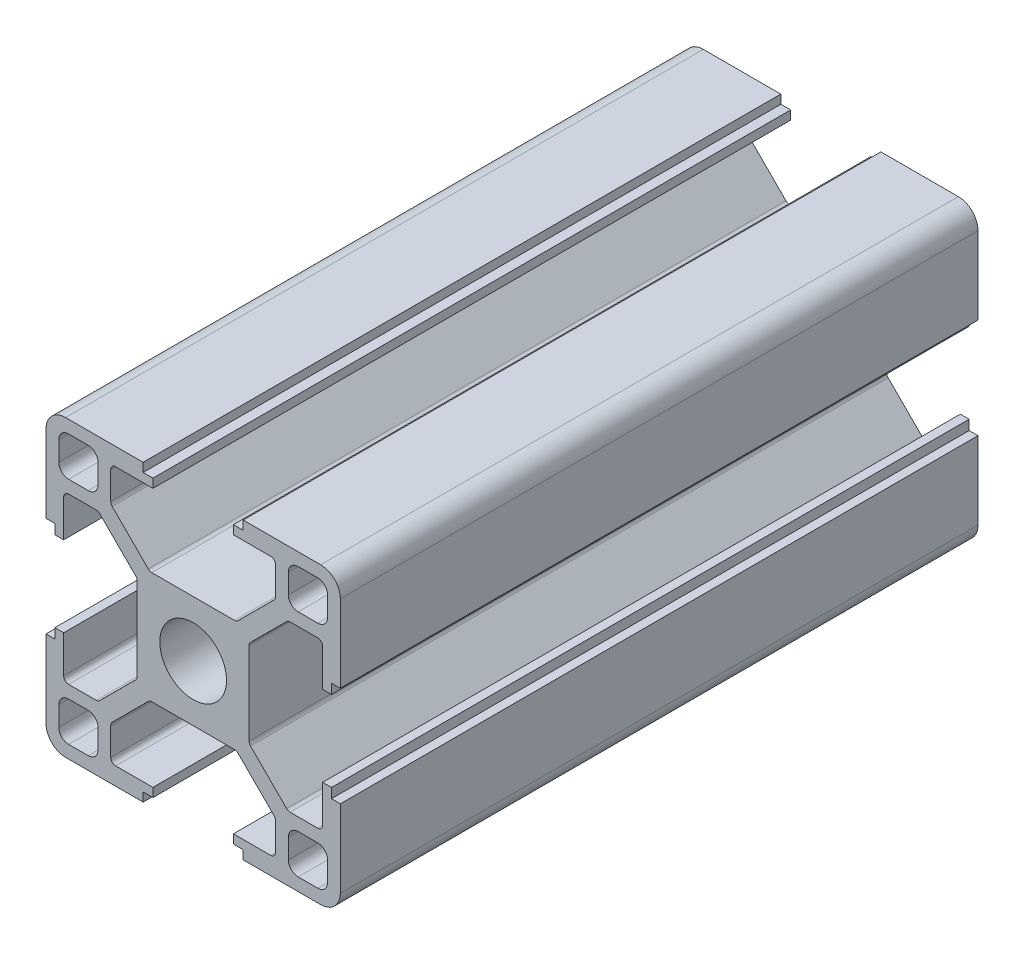
from build123d import *

# Parameters (mm, degrees)
SKETCH_1_W                       = 4
SKETCH_1_H                       = 4
EXTRUDE_1_DEPTH                  = 65
FILLET_1_R                       = 1
FILLET_2_R                       = 2
FILLET_3_R                       = 0.5
PATTERN_CIRCULAR_1_COUNT         = 4
FILLET_1_OF_PATTERN_CIRCULAR_1_R = 1
FILLET_2_OF_PATTERN_CIRCULAR_1_R = 2
FILLET_3_OF_PATTERN_CIRCULAR_1_R = 0.5
SKETCH_2_R                       = 3.4
CUT_EXTRUDE_1_DEPTH              = 66
SKETCH_3_R                       = 4.1
CUT_EXTRUDE_2_DEPTH              = 21.7


with BuildPart() as part:
    # 草图1 → 凸台-拉伸1 (new body)
    with BuildSketch(Plane.XY):
        Polygon((5.7, 0), (5.7, 4.427207794), (9.672792206, 8.4), (13.2, 8.4), (13.2, 4.1), (14.1, 4.1), (14.1, 5.1), (15, 5.1), (15, 15), (5.1, 15), (5.1, 14.1), (4.1, 14.1), (4.1, 13.2), (8.4, 13.2), (8.4, 9.672792206), (4.427207794, 5.7), (0, 5.7), (0, 0), align=None)
        with Locations((11.7, 11.7)):
            Rectangle(SKETCH_1_W, SKETCH_1_H, mode=Mode.SUBTRACT)
    extrude_1 = extrude(amount=EXTRUDE_1_DEPTH)

    # 圆角1
    fillet_1_edges = [part.edges().sort_by_distance(p)[0] for p in [
        (13.7, 9.7, 32.5),
        (13.7, 13.7, 32.5),
        (9.7, 13.7, 32.5),
        (9.7, 9.7, 32.5),
    ]]
    fillet(fillet_1_edges, radius=FILLET_1_R)

    # 圆角2
    fillet_2_edges = [part.edges().sort_by_distance(p)[0] for p in [
        (15, 15, 32.5),
    ]]
    fillet(fillet_2_edges, radius=FILLET_2_R)

    # 圆角3
    fillet_3_edges = [part.edges().sort_by_distance(p)[0] for p in [
        (4.427207794, 5.7, 32.5),
        (8.4, 9.672792206, 32.5),
        (8.4, 13.2, 32.5),
        (13.2, 8.4, 32.5),
        (9.672792206, 8.4, 32.5),
        (5.7, 4.427207794, 32.5),
    ]]
    fillet(fillet_3_edges, radius=FILLET_3_R)

    # 阵列(圆周)1: 凸台-拉伸1 ×4 about axis
    pattern_circular_1_axis = Axis((0, 0, 0), (0, 0, 1))
    for i in range(1, PATTERN_CIRCULAR_1_COUNT):
        add(extrude_1.rotate(pattern_circular_1_axis, i * 360 / PATTERN_CIRCULAR_1_COUNT))

    # 圆角1 of 阵列(圆周)1
    fillet_1_of_pattern_circular_1_edges = [part.edges().sort_by_distance(p)[0] for p in [
        (-9.7, 13.7, 32.5),
        (-13.7, 13.7, 32.5),
        (-13.7, 9.7, 32.5),
        (-9.7, 9.7, 32.5),
        (-13.7, -9.7, 32.5),
        (-13.7, -13.7, 32.5),
        (-9.7, -13.7, 32.5),
        (-9.7, -9.7, 32.5),
        (9.7, -13.7, 32.5),
        (13.7, -13.7, 32.5),
        (13.7, -9.7, 32.5),
        (9.7, -9.7, 32.5),
    ]]
    fillet(fillet_1_of_pattern_circular_1_edges, radius=FILLET_1_OF_PATTERN_CIRCULAR_1_R)

    # 圆角2 of 阵列(圆周)1
    fillet_2_of_pattern_circular_1_edges = [part.edges().sort_by_distance(p)[0] for p in [
        (-15, 15, 32.5),
        (-15, -15, 32.5),
        (15, -15, 32.5),
    ]]
    fillet(fillet_2_of_pattern_circular_1_edges, radius=FILLET_2_OF_PATTERN_CIRCULAR_1_R)

    # 圆角3 of 阵列(圆周)1
    fillet_3_of_pattern_circular_1_edges = [part.edges().sort_by_distance(p)[0] for p in [
        (-5.7, 4.427207794, 32.5),
        (-9.672792206, 8.4, 32.5),
        (-13.2, 8.4, 32.5),
        (-8.4, 13.2, 32.5),
        (-8.4, 9.672792206, 32.5),
        (-4.427207794, 5.7, 32.5),
        (-4.427207794, -5.7, 32.5),
        (-8.4, -9.672792206, 32.5),
        (-8.4, -13.2, 32.5),
        (-13.2, -8.4, 32.5),
        (-9.672792206, -8.4, 32.5),
        (-5.7, -4.427207794, 32.5),
        (5.7, -4.427207794, 32.5),
        (9.672792206, -8.4, 32.5),
        (13.2, -8.4, 32.5),
        (8.4, -13.2, 32.5),
        (8.4, -9.672792206, 32.5),
        (4.427207794, -5.7, 32.5),
    ]]
    fillet(fillet_3_of_pattern_circular_1_edges, radius=FILLET_3_OF_PATTERN_CIRCULAR_1_R)

    # 草图2 → 切除-拉伸1 (cut, through all)
    with BuildSketch(Plane.XY.offset(65)):
        Circle(SKETCH_2_R)
    extrude(amount=-CUT_EXTRUDE_1_DEPTH, mode=Mode.SUBTRACT)

    # 草图3 → 切除-拉伸2 (cut, through all)
    with BuildSketch(Plane.ZY.offset(5.7)):
        with Locations((15, 0)):
            Circle(SKETCH_3_R)
    extrude(amount=-CUT_EXTRUDE_2_DEPTH, mode=Mode.SUBTRACT)


solid = part.part
